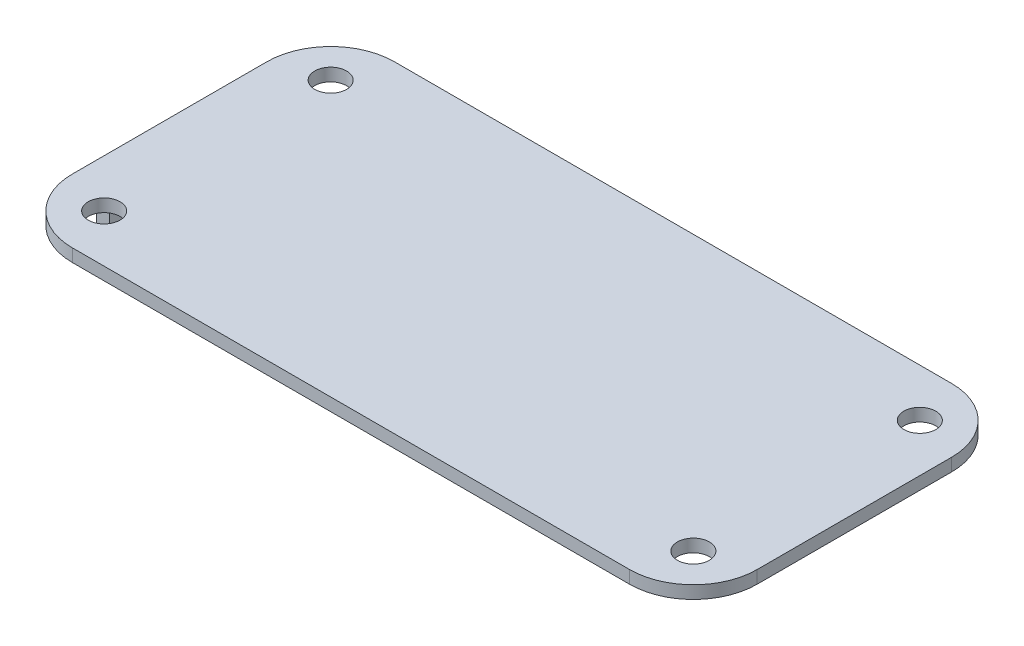
from build123d import *

# Parameters (mm, degrees)
SKETCH1_R           = 5
BOSS_EXTRUDE1_DEPTH = 4
SKETCH2_W           = 4
SKETCH2_H           = 45.7
BOSS_EXTRUDE2_DEPTH = 21.3


with BuildPart() as part:
    # Sketch1 → Boss-Extrude1 (new body)
    with BuildSketch(Plane(origin=(0, 0, 0), x_dir=(1, 0, 0), z_dir=(0, 1, 0))):
        with BuildLine():
            Line((-87.35, -50.5), (87.35, -50.5))
            ThreePointArc((87.35, -50.5), (101.492135624, -44.642135624), (107.35, -30.5))
            Line((107.35, -30.5), (107.35, 30.5))
            ThreePointArc((107.35, 30.5), (101.492135624, 44.642135624), (87.35, 50.5))
            Line((87.35, 50.5), (-87.35, 50.5))
            ThreePointArc((-87.35, 50.5), (-101.492135624, 44.642135624), (-107.35, 30.5))
            Line((-107.35, 30.5), (-107.35, -30.5))
            ThreePointArc((-107.35, -30.5), (-101.492135624, -44.642135624), (-87.35, -50.5))
        make_face()
        with Locations((-92.35, 35.5)):
            Circle(SKETCH1_R, mode=Mode.SUBTRACT)
        with Locations((92.35, 35.5)):
            Circle(SKETCH1_R, mode=Mode.SUBTRACT)
        with Locations((92.35, -35.5)):
            Circle(SKETCH1_R, mode=Mode.SUBTRACT)
        with Locations((-92.35, -35.5)):
            Circle(SKETCH1_R, mode=Mode.SUBTRACT)
    extrude(amount=BOSS_EXTRUDE1_DEPTH)

    # Sketch2 → Boss-Extrude2 (add)
    with BuildSketch(Plane(origin=(0, 4, 0), x_dir=(1, 0, 0), z_dir=(0, 1, 0))):
        with Locations((-105.35, 0)):
            Rectangle(SKETCH2_W, SKETCH2_H)
    extrude(amount=-BOSS_EXTRUDE2_DEPTH)


solid = part.part
